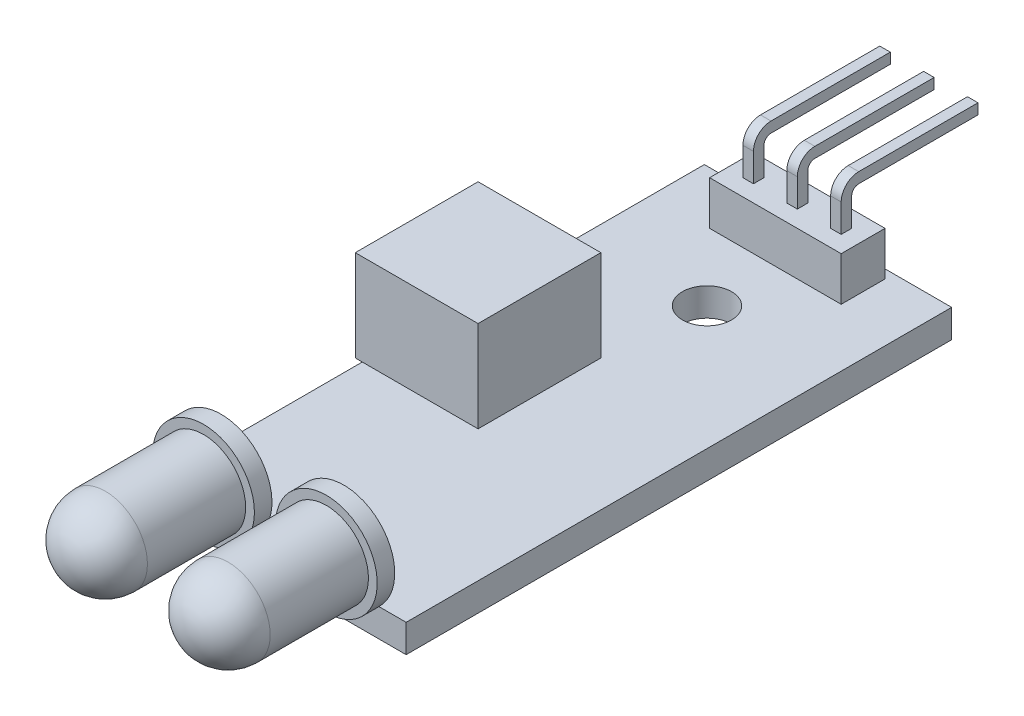
from build123d import *

# Parameters (mm, degrees)
SKETCH_1_W                 = 14.1
SKETCH_1_H                 = 31.1
SKETCH_1_R                 = 1.4
EXTRUDE_1_DEPTH            = 1.6
SKETCH_2_R                 = 2.9
EXTRUDE_2_DEPTH            = 1
SKETCH_3_R                 = 2.4
EXTRUDE_3_DEPTH            = 8
FILLET_1_R                 = 2.4
FILLET_1_OF_MIRROR_1_R     = 2.4
SKETCH_4_W                 = 7
SKETCH_4_H                 = 7
EXTRUDE_4_DEPTH            = 5.2
SKETCH_5_W                 = 2.5
SKETCH_5_H                 = 2.5
EXTRUDE_5_DEPTH            = 2.5
EXTRUDE_6_DEPTH            = 0.3
PATTERN_LINEAR_1_COUNT     = 2
PATTERN_LINEAR_1_PITCH     = 2.5
PATTERN_LINEAR_1_COL_COUNT = 2
PATTERN_LINEAR_1_COL_PITCH = 2.5


with BuildPart() as part:
    # 草图1 → 凸台-拉伸1 (new body)
    with BuildSketch(Plane(origin=(0, 0, 0), x_dir=(1, 0, 0), z_dir=(0, 1, 0))):
        Rectangle(SKETCH_1_W, SKETCH_1_H)
        with Locations((0, 8.65)):
            Circle(SKETCH_1_R, mode=Mode.SUBTRACT)
    extrude(amount=EXTRUDE_1_DEPTH)

    # 草图2 → 凸台-拉伸2 (add)
    with BuildSketch(Plane.XY.offset(15.55)):
        with Locations((-3.5, 3.7)):
            Circle(SKETCH_2_R)
    extrude_2 = extrude(amount=EXTRUDE_2_DEPTH)

    # 草图3 → 凸台-拉伸3 (add)
    with BuildSketch(Plane.XY.offset(16.55)):
        with Locations((-3.5, 3.7)):
            Circle(SKETCH_3_R)
    extrude_3 = extrude(amount=EXTRUDE_3_DEPTH)

    # 圆角1
    fillet_1_edges = [part.edges().sort_by_distance(p)[0] for p in [
        (-5.9, 3.7, 24.55),
    ]]
    fillet(fillet_1_edges, radius=FILLET_1_R)

    # 镜向1: 凸台-拉伸2, 凸台-拉伸3 across plane
    add(extrude_2.mirror(Plane(origin=(0, 0, 0), x_dir=(0, 0, 1), z_dir=(1, 0, 0))))
    add(extrude_3.mirror(Plane(origin=(0, 0, 0), x_dir=(0, 0, 1), z_dir=(1, 0, 0))))

    # 圆角1 of 镜向1
    fillet_1_of_mirror_1_edges = [part.edges().sort_by_distance(p)[0] for p in [
        (5.9, 3.7, 24.55),
    ]]
    fillet(fillet_1_of_mirror_1_edges, radius=FILLET_1_OF_MIRROR_1_R)

    # 草图4 → 凸台-拉伸4 (add)
    with BuildSketch(Plane(origin=(0, 1.6, 0), x_dir=(1, 0, 0), z_dir=(0, 1, 0))):
        with Locations((-3.95, -0.45)):
            Rectangle(SKETCH_4_W, SKETCH_4_H)
    extrude(amount=EXTRUDE_4_DEPTH)

    # 草图5 → 凸台-拉伸5 (add)
    with BuildSketch(Plane(origin=(0, 1.6, 0), x_dir=(1, 0, 0), z_dir=(0, 1, 0))):
        with Locations((0, 13.8)):
            Rectangle(SKETCH_5_W, SKETCH_5_H)
    extrude_5 = extrude(amount=EXTRUDE_5_DEPTH)

    # 草图6 → 凸台-拉伸6 (add, symmetric)
    with BuildSketch(Plane(origin=(0, 0, 0), x_dir=(0, 0, -1), z_dir=(1, 0, 0))):
        with BuildLine():
            Line((13.5, -0.5), (13.5, 5.7))
            ThreePointArc((13.5, 5.7), (13.792893219, 6.407106781), (14.5, 6.7))
            Line((14.5, 6.7), (21.3, 6.7))
            Line((21.3, 6.7), (21.3, 6.1))
            Line((21.3, 6.1), (14.5, 6.1))
            ThreePointArc((14.5, 6.1), (14.217157288, 5.982842712), (14.1, 5.7))
            Line((14.1, 5.7), (14.1, -0.5))
            Line((14.1, -0.5), (13.5, -0.5))
        make_face()
    extrude_6 = extrude(amount=EXTRUDE_6_DEPTH, both=True)

    # 阵列(线性)1: 凸台-拉伸5, 凸台-拉伸6 ×2
    with Locations(*[(-i * PATTERN_LINEAR_1_PITCH, 0, 0) for i in range(1, PATTERN_LINEAR_1_COUNT)]):
        add(extrude_5)
        add(extrude_6)

    # 阵列(线性)1 col: 凸台-拉伸5, 凸台-拉伸6 ×2
    with Locations(*[(i * PATTERN_LINEAR_1_COL_PITCH, 0, 0) for i in range(1, PATTERN_LINEAR_1_COL_COUNT)]):
        add(extrude_5)
        add(extrude_6)


solid = part.part
